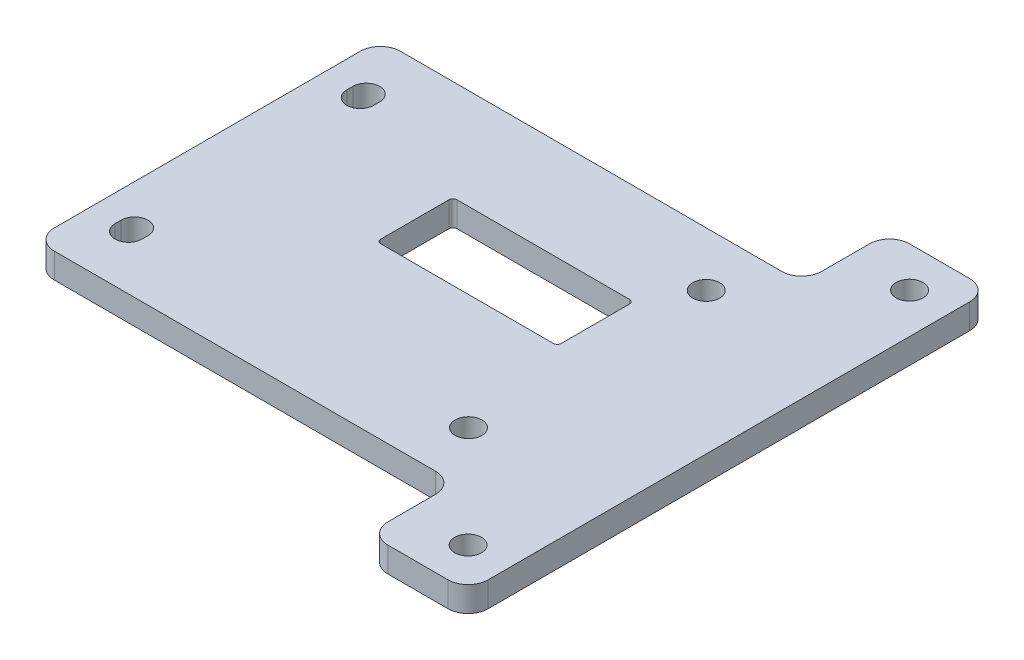
from build123d import *

# Parameters (mm, degrees)
SKETCH1_W            = 66.04
SKETCH1_H            = 43.815
BOSS_EXTRUDE1_DEPTH  = 3.175
M3_CLEARANCE_HOLE1_D = 3.4
SKETCH6_W            = 22.86
SKETCH6_H            = 9.652
CUT_EXTRUDE1_DEPTH   = 4.175
FILLET1_R            = 0.508
FILLET2_R            = 2.54
SKETCH7_W            = 12.7
SKETCH7_H            = 66.04
BOSS_EXTRUDE2_DEPTH  = 3.175
M3_CLEARANCE_HOLE2_D = 3.4
FILLET3_R            = 2.54
CUT_EXTRUDE2_DEPTH   = 4.175


with BuildPart() as part:
    # Sketch1 → Boss-Extrude1 (new body)
    with BuildSketch(Plane(origin=(0, 0, 0), x_dir=(1, 0, 0), z_dir=(0, 1, 0))):
        with Locations((33.02, 21.9075)):
            Rectangle(SKETCH1_W, SKETCH1_H)
    extrude(amount=BOSS_EXTRUDE1_DEPTH)

    # M3 Clearance Hole1 (through all)
    with Locations(Plane(origin=(0, 0, 0), x_dir=(-1, 0, 0), z_dir=(0, -1, 0))):
        with Locations((-5.08, 6.858), (-5.08, 36.957), (-48.1203, 36.957), (-48.1203, 6.858), (-60.96, 6.858), (-60.96, 36.957)):
            Hole(M3_CLEARANCE_HOLE1_D / 2)

    # Sketch6 → Cut-Extrude1 (cut, through all)
    with BuildSketch(Plane(origin=(0, 3.175, 0), x_dir=(1, 0, 0), z_dir=(0, 1, 0))):
        with Locations((33.3248, 26.289)):
            Rectangle(SKETCH6_W, SKETCH6_H)
    extrude(amount=-CUT_EXTRUDE1_DEPTH, mode=Mode.SUBTRACT)

    # Fillet1
    fillet1_edges = [part.edges().sort_by_distance(p)[0] for p in [
        (44.7548, 1.5875, -21.463),
        (21.8948, 1.5875, -21.463),
        (21.8948, 1.5875, -31.115),
        (44.7548, 1.5875, -31.115),
    ]]
    fillet(fillet1_edges, radius=FILLET1_R)

    # Fillet2
    fillet2_edges = [part.edges().sort_by_distance(p)[0] for p in [
        (0, 1.5875, -43.815),
        (66.04, 1.5875, -43.815),
        (66.04, 1.5875, 0),
        (0, 1.5875, 0),
    ]]
    fillet(fillet2_edges, radius=FILLET2_R)

    # Sketch7 → Boss-Extrude2 (add)
    with BuildSketch(Plane(origin=(0, 3.175, 0), x_dir=(1, 0, 0), z_dir=(0, 1, 0))):
        with Locations((59.69, 21.9075)):
            Rectangle(SKETCH7_W, SKETCH7_H)
    extrude(amount=-BOSS_EXTRUDE2_DEPTH)

    # M3 Clearance Hole2 (through all)
    with Locations(Plane(origin=(0, 3.175, 0), x_dir=(1, 0, 0), z_dir=(0, 1, 0))):
        with Locations((60.96, 49.8475), (60.96, -6.0325)):
            Hole(M3_CLEARANCE_HOLE2_D / 2)

    # Fillet3
    fillet3_edges = [part.edges().sort_by_distance(p)[0] for p in [
        (53.34, 1.5875, 11.1125),
        (66.04, 1.5875, -54.9275),
        (53.34, 1.5875, -54.9275),
        (53.34, 1.5875, 0),
        (53.34, 1.5875, -43.815),
        (66.04, 1.5875, 11.1125),
    ]]
    fillet(fillet3_edges, radius=FILLET3_R)

    # Sketch11 → Cut-Extrude2 (cut, through all)
    with BuildSketch(Plane.XZ):
        with BuildLine():
            Line((3.38, -6.858), (3.38, -7.62))
            ThreePointArc((3.38, -7.62), (5.08, -9.32), (6.78, -7.62))
            Line((6.78, -7.62), (6.78, -6.858))
            ThreePointArc((6.78, -6.858), (5.08, -5.158), (3.38, -6.858))
        make_face()
        with BuildLine():
            Line((6.78, -36.195), (6.78, -36.957))
            ThreePointArc((6.78, -36.957), (5.08, -38.657), (3.38, -36.957))
            Line((3.38, -36.957), (3.38, -36.195))
            ThreePointArc((3.38, -36.195), (5.08, -34.495), (6.78, -36.195))
        make_face()
    extrude(amount=-CUT_EXTRUDE2_DEPTH, mode=Mode.SUBTRACT)


solid = part.part
